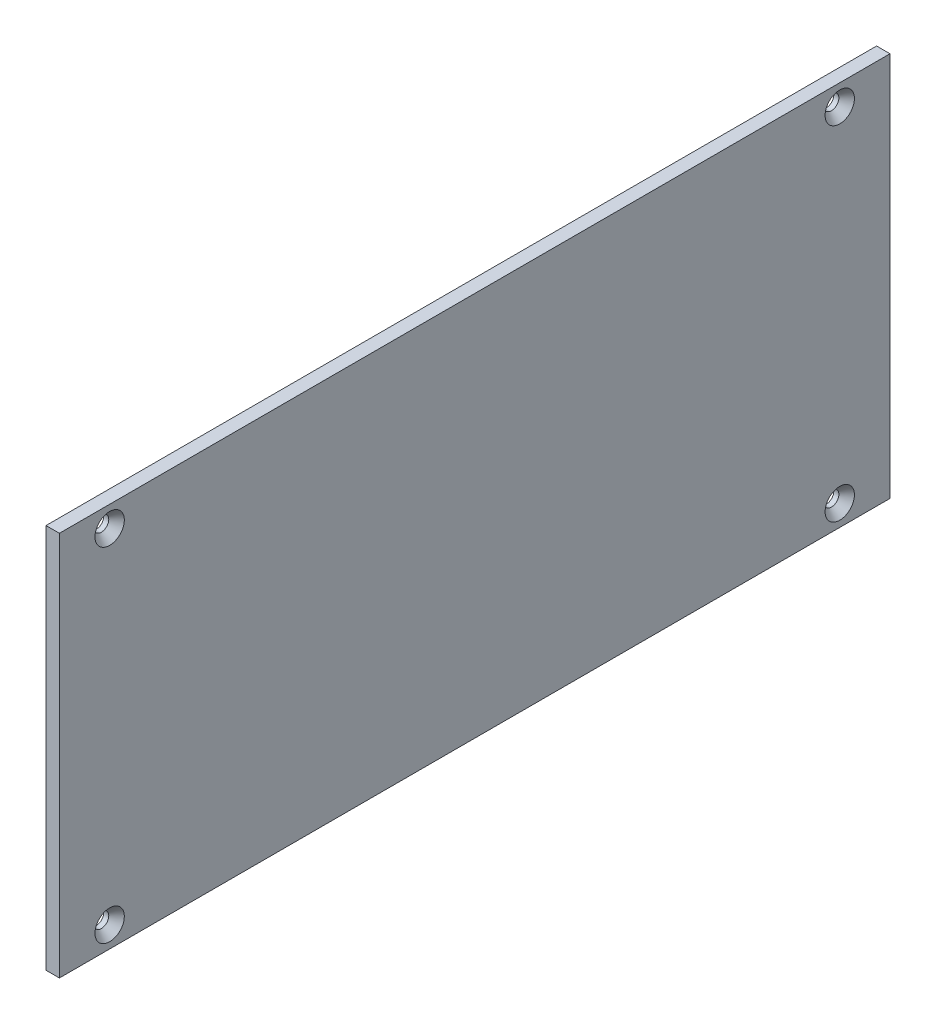
from build123d import *

# Parameters (mm, degrees)
SKETCH1_W                                     = 99.2004
SKETCH1_H                                     = 46
BOSS_EXTRUDE1_DEPTH                           = 1.6002
CSK_FOR_0_FLAT_HEAD_SOCKET_CAP_SCREW1_A_COUNT = 2
CSK_FOR_0_FLAT_HEAD_SOCKET_CAP_SCREW1_A_PITCH = 41
CSK_FOR_0_FLAT_HEAD_SOCKET_CAP_SCRE_2_COUNT   = 2
CSK_FOR_0_FLAT_HEAD_SOCKET_CAP_SCRE_2_PITCH   = 96.358236597
CSK_FOR_0_FLAT_HEAD_SOCKET_CAP_SCRE_3_COUNT   = 2
CSK_FOR_0_FLAT_HEAD_SOCKET_CAP_SCRE_3_PITCH   = 87.2004


with BuildPart() as part:
    # Sketch1 → Boss-Extrude1 (new body)
    with BuildSketch(Plane(origin=(0, 0, 0), x_dir=(0, 0, -1), z_dir=(1, 0, 0))):
        with Locations((49.6002, 23)):
            Rectangle(SKETCH1_W, SKETCH1_H)
    extrude(amount=BOSS_EXTRUDE1_DEPTH)

    # Sketch4 → CSK for #0 Flat Head Socket Cap Screw1 (revolve, cut)
    with BuildSketch(Plane(origin=(1.6002, 43.5, -6), x_dir=(0, 0, -1), z_dir=(0, 1, 0))):
        Polygon((0, 0), (0, 1.6002), (0.889, 1.6002), (0.889, 0.993458156), (1.7526, 0), align=None)
    csk_for_0_flat_head_socket_cap_screw1 = revolve(axis=Axis((7.9502, 43.5, -6), (-1, 0, 0)), mode=Mode.SUBTRACT)

    # CSK for #0 Flat Head Socket Cap Screw1 a: CSK for #0 Flat Head Socket Cap Screw1 ×2
    with Locations(*[(0, -i * CSK_FOR_0_FLAT_HEAD_SOCKET_CAP_SCREW1_A_PITCH, 0) for i in range(1, CSK_FOR_0_FLAT_HEAD_SOCKET_CAP_SCREW1_A_COUNT)]):
        add(csk_for_0_flat_head_socket_cap_screw1, mode=Mode.SUBTRACT)

    # CSK for _0 Flat Head Socket Cap Scre 2: CSK for #0 Flat Head Socket Cap Screw1 ×2
    with Locations(*[Vector(0, -0.425495541, -0.904960521) * (i * CSK_FOR_0_FLAT_HEAD_SOCKET_CAP_SCRE_2_PITCH) for i in range(1, CSK_FOR_0_FLAT_HEAD_SOCKET_CAP_SCRE_2_COUNT)]):
        add(csk_for_0_flat_head_socket_cap_screw1, mode=Mode.SUBTRACT)

    # CSK for _0 Flat Head Socket Cap Scre 3: CSK for #0 Flat Head Socket Cap Screw1 ×2
    with Locations(*[(0, 0, -i * CSK_FOR_0_FLAT_HEAD_SOCKET_CAP_SCRE_3_PITCH) for i in range(1, CSK_FOR_0_FLAT_HEAD_SOCKET_CAP_SCRE_3_COUNT)]):
        add(csk_for_0_flat_head_socket_cap_screw1, mode=Mode.SUBTRACT)


solid = part.part
